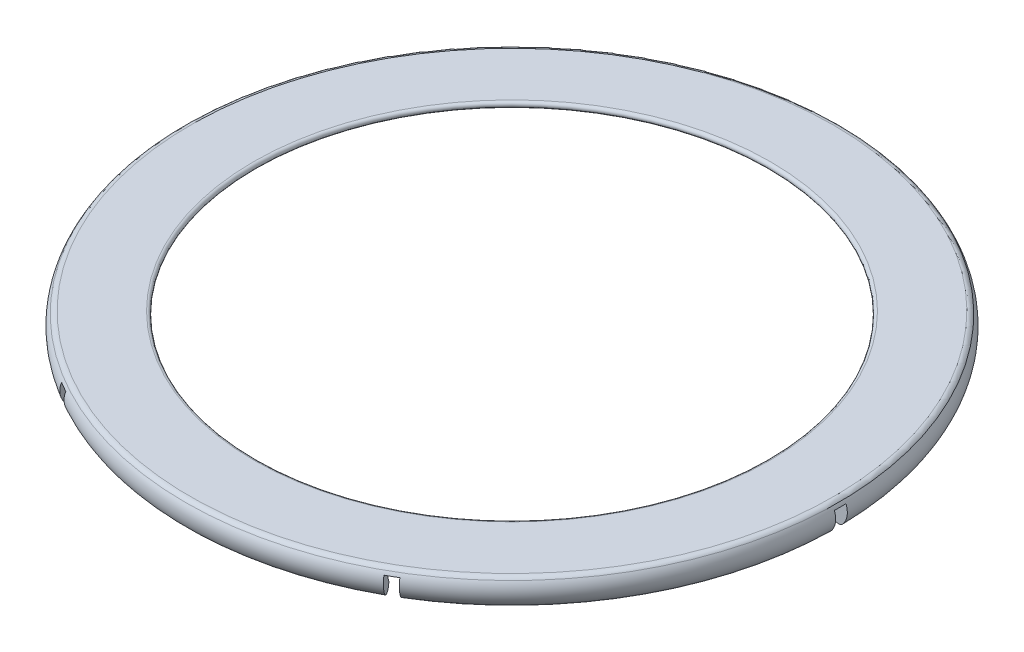
from build123d import *

# Parameters (mm, degrees)
SKETCH2_W          = 76.762463064
SKETCH2_H          = 1
CUT_EXTRUDE1_DEPTH = 11.684
CIRPATTERN1_COUNT  = 3
FILLET1_R          = 0.5


with BuildPart() as part:
    # Sketch1 → Revolve1 (revolve)
    with BuildSketch(Plane.XY, mode=Mode.PRIVATE) as revolve1_sk:
        with BuildLine():
            Line((-26.664658343, 4.6), (-27.826553347, 4.6))
            ThreePointArc((-27.826553347, 4.6), (-28.263940577, 3.547920085), (-27.890329452, 2.471539825))
            ThreePointArc((-27.890329452, 2.471539825), (-27.185913426, 2.409911408), (-27.124285009, 3.114327434))
            ThreePointArc((-27.124285009, 3.114327434), (-27.208443015, 3.753570957), (-26.664658343, 4.1))
            Line((-26.664658343, 4.1), (-22.164658343, 4.1))
            ThreePointArc((-22.164658343, 4.1), (-21.914658343, 4.35), (-22.164658343, 4.6))
            Line((-22.164658343, 4.6), (-26.664658343, 4.6))
        make_face()
    revolve(revolve1_sk.sketch.rotate(Axis((0, 0, 0), (0, 1, 0)), 270), axis=Axis((0, 0, 0), (0, 1, 0)))

    # Sketch2 → Cut-Extrude1 (cut)
    with BuildSketch(Plane.XZ.offset(-4.1)):
        Rectangle(SKETCH2_W, SKETCH2_H)
    cut_extrude1 = extrude(amount=CUT_EXTRUDE1_DEPTH, mode=Mode.SUBTRACT)

    # CirPattern1: Cut-Extrude1 ×3 about axis
    cirpattern1_axis = Axis((0, 0, 0), (0, 1, 0))
    for i in range(1, CIRPATTERN1_COUNT):
        add(cut_extrude1.rotate(cirpattern1_axis, i * 360 / CIRPATTERN1_COUNT), mode=Mode.SUBTRACT)

    # Fillet1
    fillet1_edges = [part.edges().sort_by_distance(p)[0] for p in [
        (0, 4.6, 27.826553347),
    ]]
    fillet(fillet1_edges, radius=FILLET1_R)


solid = part.part
